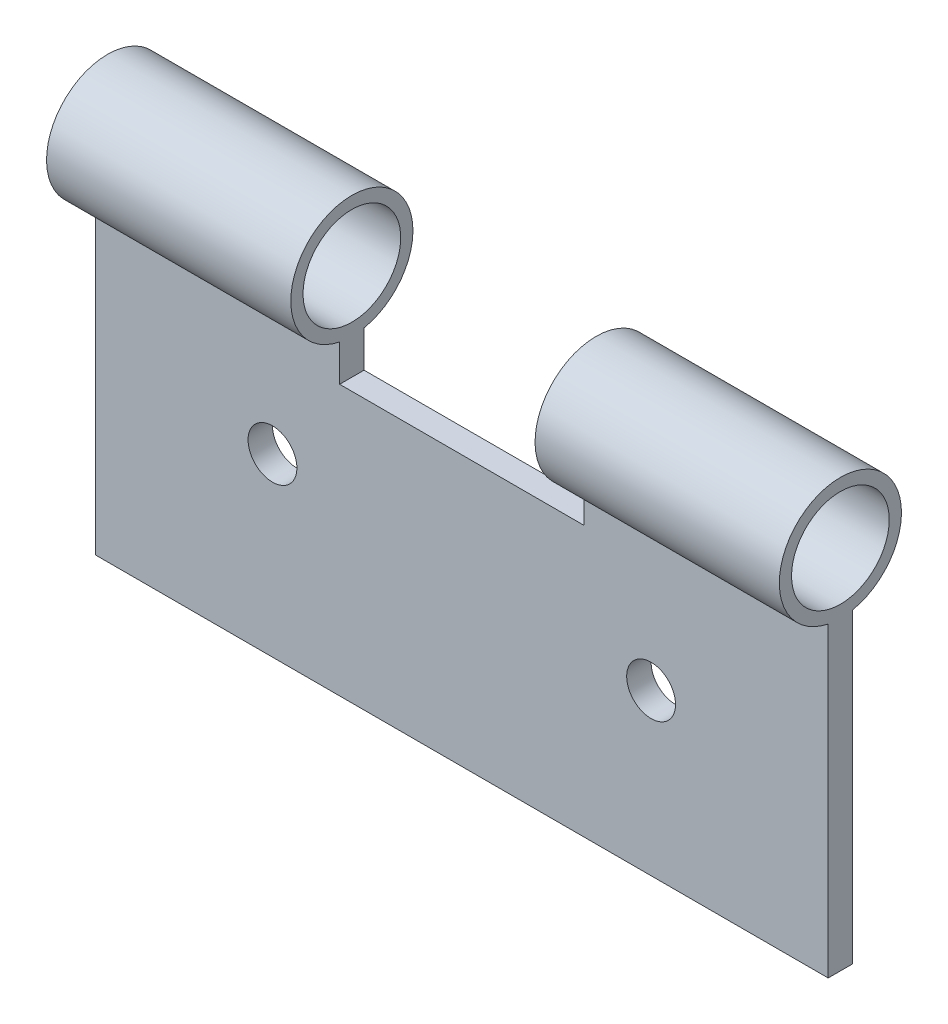
from build123d import *

# Parameters (mm, degrees)
SKETCH_2_R               = 0.2
EXTRUDE_1_DEPTH          = 3
SKETCH_3_R               = 0.1
CUT_EXTRUDE_1_DEPTH      = 3
CUT_EXTRUDE_2_DEPTH      = 3
CUT_EXTRUDE_2_DEPTH_BACK = 3
SKETCH_4_W               = 1
SKETCH_4_H               = 1.358219005


with BuildPart() as part:
    # 草图2 → 凸台-拉伸1 (new body)
    with BuildSketch(Plane(origin=(0, 0, 0), x_dir=(0, 0, -1), z_dir=(1, 0, 0))):
        with BuildLine():
            Line((-0.05, 0.505051026), (-0.05, -0.75))
            Line((-0.05, -0.75), (0.05, -0.75))
            Line((0.05, -0.75), (0.05, 0.505051026))
            ThreePointArc((0.05, 0.505051026), (0, 1), (-0.05, 0.505051026))
        make_face()
        with Locations((0, 0.75)):
            Circle(SKETCH_2_R, mode=Mode.SUBTRACT)
    extrude(amount=EXTRUDE_1_DEPTH)

    # 草图3 → 切除-拉伸1 (cut)
    with BuildSketch(Plane(origin=(0, 0, -0.05), x_dir=(-1, 0, 0), z_dir=(0, 0, -1))):
        with Locations((-2.275, -0.092876486)):
            Circle(SKETCH_3_R)
        with Locations((-0.725, -0.029598001)):
            Circle(SKETCH_3_R)
    extrude(amount=-CUT_EXTRUDE_1_DEPTH, mode=Mode.SUBTRACT)

    # 草图4 → 切除-拉伸2 (cut, two sides: drawn at the far end of the back side and taken through both)
    with BuildSketch(Plane.XY.offset(0.05).offset(-CUT_EXTRUDE_2_DEPTH_BACK)):
        with Locations((1.5, 1.034160529)):
            Rectangle(SKETCH_4_W, SKETCH_4_H)
    extrude(amount=CUT_EXTRUDE_2_DEPTH + CUT_EXTRUDE_2_DEPTH_BACK, mode=Mode.SUBTRACT)


solid = part.part
